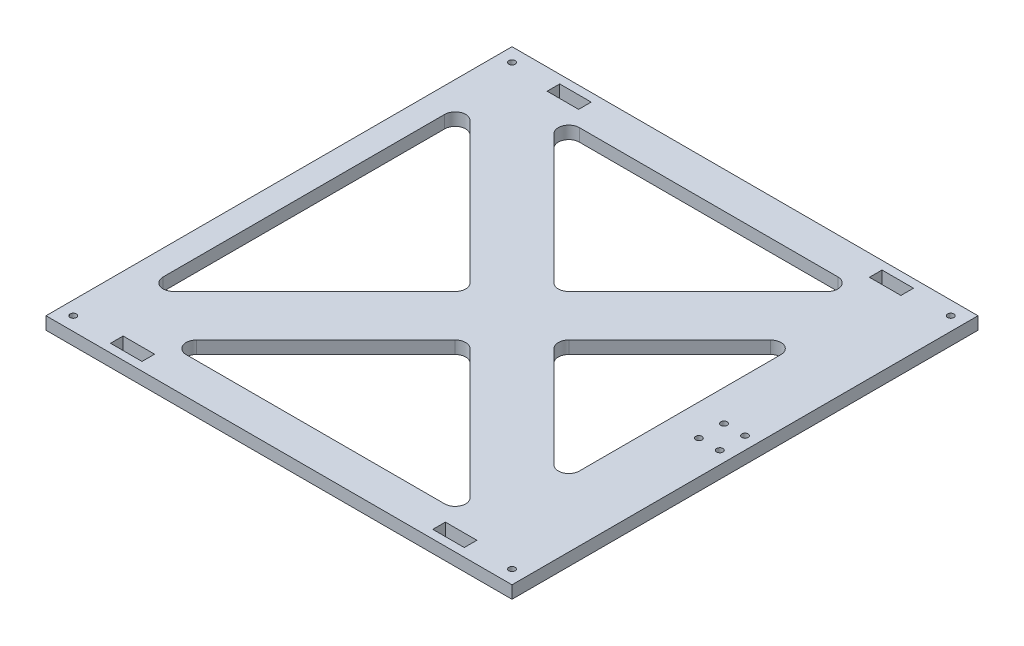
from build123d import *

# Parameters (mm, degrees)
SKETCH_1_R      = 1.5
SKETCH_1_W      = 14.999960721
SKETCH_1_H      = 6.000098196
SKETCH_1_H_2    = 6.000098195
SKETCH_1_W_2    = 14.999960722
EXTRUDE_1_DEPTH = 6


with BuildPart() as part:
    # Эскиз1 → Бобышка-Вытянуть1 (new body)
    with BuildSketch(Plane(origin=(0, 0, 0), x_dir=(1, 0, 0), z_dir=(0, 1, 0))):
        Polygon((-102.768102854, -104.532435011), (-102.768102854, -92.192478988), (-102.768102854, -82.192478988), (-102.768102854, 85.127608967), (-102.768102854, 95.127608967), (-102.768102854, 107.467564989), (-102.768102854, 112.467564989), (-97.768102854, 112.467564989), (114.231897146, 112.467564989), (119.231897146, 112.467564989), (119.231897146, 107.467564989), (119.231897146, -104.532435011), (119.231897146, -109.532435011), (114.231897146, -109.532435011), (-97.768102854, -109.532435011), (-102.768102854, -109.532435011), align=None)
        with Locations((-96.268102854, 105.967564989)):
            Circle(SKETCH_1_R, mode=Mode.SUBTRACT)
        with Locations((112.731897146, 105.967564989)):
            Circle(SKETCH_1_R, mode=Mode.SUBTRACT)
        with Locations((-96.268102854, -103.032435011)):
            Circle(SKETCH_1_R, mode=Mode.SUBTRACT)
        with Locations((112.731897146, -103.032435011)):
            Circle(SKETCH_1_R, mode=Mode.SUBTRACT)
        with Locations((103.231897146, 7.467564989)):
            Circle(SKETCH_1_R, mode=Mode.SUBTRACT)
        with Locations((113.231897146, 7.467564989)):
            Circle(SKETCH_1_R, mode=Mode.SUBTRACT)
        with Locations((113.231897146, -4.532435011)):
            Circle(SKETCH_1_R, mode=Mode.SUBTRACT)
        with Locations((103.231897146, -4.532435011)):
            Circle(SKETCH_1_R, mode=Mode.SUBTRACT)
        with Locations((-68.539568551, 105.467614087)):
            Rectangle(SKETCH_1_W, SKETCH_1_H, mode=Mode.SUBTRACT)
        with Locations((-68.539568551, -102.532484109)):
            Rectangle(SKETCH_1_W, SKETCH_1_H_2, mode=Mode.SUBTRACT)
        with BuildLine():
            Line((-15.30363676, 5.003098895), (-63.336645349, 53.036107484))
            Line((-63.336645349, 53.036107484), (-82.344918946, 72.044381082))
            ThreePointArc((-82.344918946, 72.044381082), (-87.793870014, 73.128244838), (-90.880452852, 68.508847176))
            Line((-90.880452852, 68.508847176), (-90.880452852, -65.573717197))
            ThreePointArc((-90.880452852, -65.573717197), (-87.793870014, -70.193114859), (-82.344918946, -69.109251103))
            Line((-82.344918946, -69.109251103), (-63.336645349, -50.100977505))
            Line((-63.336645349, -50.100977505), (-15.30363676, -2.067968916))
            ThreePointArc((-15.30363676, -2.067968916), (-13.839170666, 1.467564989), (-15.30363676, 5.003098895))
        make_face(mode=Mode.SUBTRACT)
        with BuildLine():
            Line((31.767431052, 5.003098895), (79.800439641, 53.036107484))
            ThreePointArc((79.800439641, 53.036107484), (85.249390708, 54.119971241), (88.335973547, 49.500573578))
            Line((88.335973547, 49.500573578), (88.335973547, -46.5654436))
            ThreePointArc((88.335973547, -46.5654436), (85.249390708, -51.184841262), (79.800439641, -50.100977505))
            Line((79.800439641, -50.100977505), (31.767431052, -2.067968916))
            ThreePointArc((31.767431052, -2.067968916), (30.302964958, 1.467564989), (31.767431052, 5.003098895))
        make_face(mode=Mode.SUBTRACT)
        with BuildLine():
            Line((4.69636324, 25.003098895), (-43.336645349, 73.036107484))
            Line((-43.336645349, 73.036107484), (-56.892612926, 86.592075061))
            ThreePointArc((-56.892612926, 86.592075061), (-57.976476682, 92.041026129), (-53.35707902, 95.127608967))
            Line((-53.35707902, 95.127608967), (69.820873311, 95.127608967))
            ThreePointArc((69.820873311, 95.127608967), (74.440270974, 92.041026129), (73.356407217, 86.592075061))
            Line((73.356407217, 86.592075061), (59.800439641, 73.036107484))
            Line((59.800439641, 73.036107484), (11.767431052, 25.003098895))
            ThreePointArc((11.767431052, 25.003098895), (8.231897146, 23.538632801), (4.69636324, 25.003098895))
        make_face(mode=Mode.SUBTRACT)
        with BuildLine():
            Line((69.820873311, -92.192478988), (-53.35707902, -92.192478988))
            ThreePointArc((-53.35707902, -92.192478988), (-57.976476682, -89.10589615), (-56.892612926, -83.656945082))
            Line((-56.892612926, -83.656945082), (-43.336645349, -70.100977505))
            Line((-43.336645349, -70.100977505), (4.69636324, -22.067968916))
            ThreePointArc((4.69636324, -22.067968916), (8.231897146, -20.603502822), (11.767431052, -22.067968916))
            Line((11.767431052, -22.067968916), (59.800439641, -70.100977505))
            Line((59.800439641, -70.100977505), (73.356407217, -83.656945082))
            ThreePointArc((73.356407217, -83.656945082), (74.440270974, -89.10589615), (69.820873311, -92.192478988))
        make_face(mode=Mode.SUBTRACT)
        with Locations((85.003362843, -102.532484109)):
            Rectangle(SKETCH_1_W_2, SKETCH_1_H_2, mode=Mode.SUBTRACT)
        with Locations((85.003362843, 105.467614087)):
            Rectangle(SKETCH_1_W_2, SKETCH_1_H, mode=Mode.SUBTRACT)
    extrude(amount=EXTRUDE_1_DEPTH)


solid = part.part
